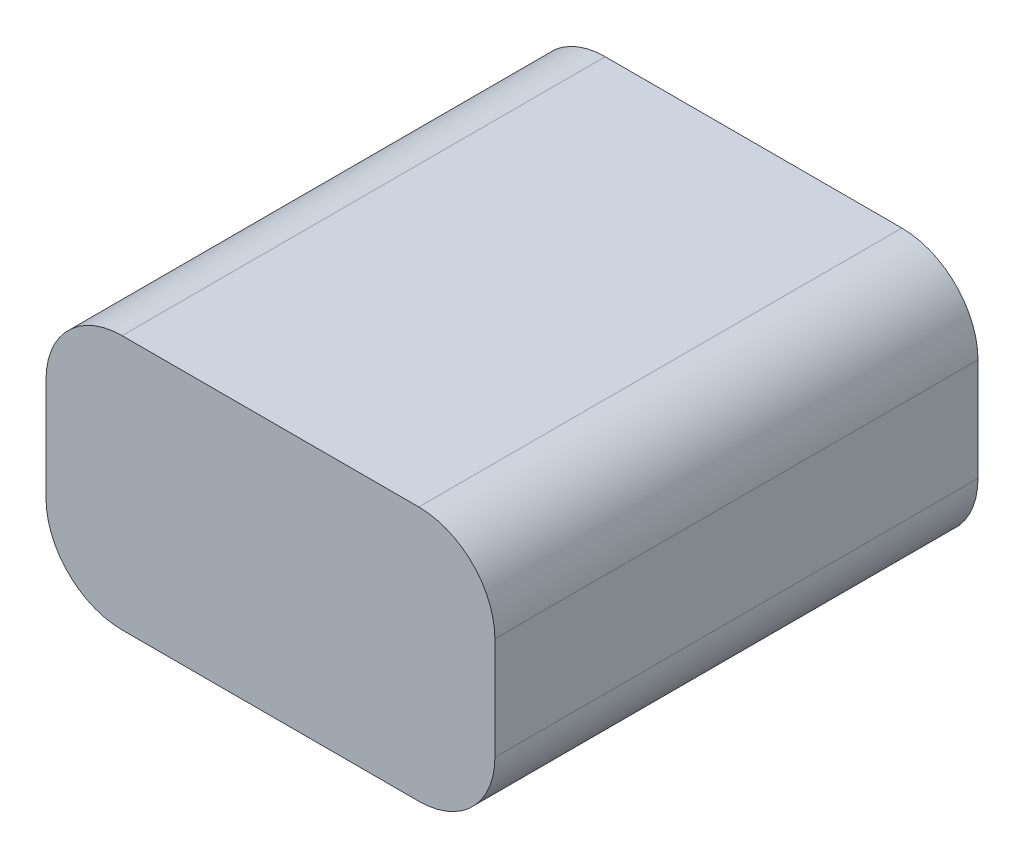
from build123d import *

# Parameters (mm, degrees)
SKETCH1_W           = 59
SKETCH1_H           = 63.5
BOSS_EXTRUDE1_DEPTH = 33.5
FILLET1_R           = 10


with BuildPart() as part:
    # Sketch1 → Boss-Extrude1 (new body)
    with BuildSketch(Plane(origin=(0, 0, 0), x_dir=(1, 0, 0), z_dir=(0, 1, 0))):
        Rectangle(SKETCH1_W, SKETCH1_H)
    extrude(amount=BOSS_EXTRUDE1_DEPTH)

    # Fillet1
    fillet1_edges = [part.edges().sort_by_distance(p)[0] for p in [
        (29.5, 33.5, 0),
        (-29.5, 33.5, 0),
        (29.5, 0, 0),
        (-29.5, 0, 0),
    ]]
    fillet(fillet1_edges, radius=FILLET1_R)


solid = part.part
